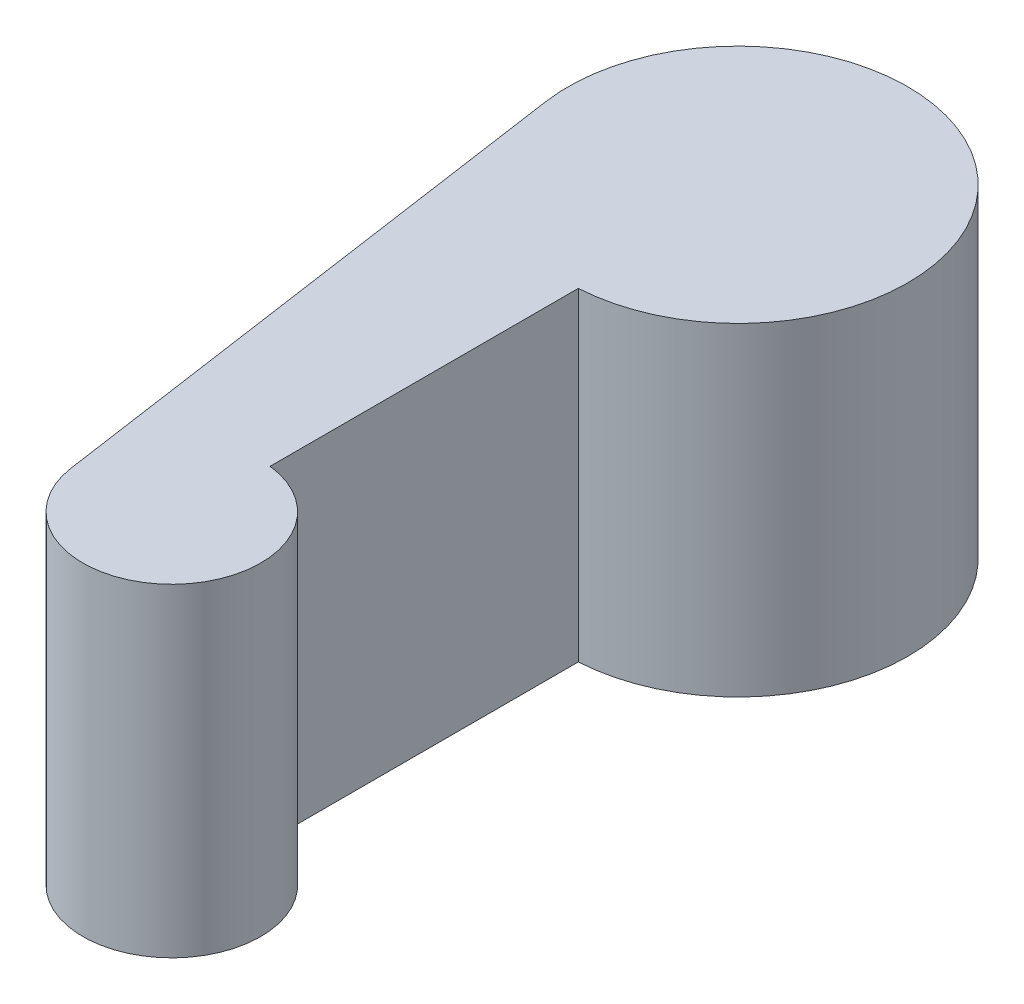
from build123d import *

# Parameters (mm, degrees)
BOSS_EXTRUDE1_DEPTH = 40


with BuildPart() as part:
    # Sketch1 → Boss-Extrude1 (new body)
    with BuildSketch(Plane(origin=(0, 0, 0), x_dir=(1, 0, 0), z_dir=(0, 1, 0))):
        with BuildLine():
            Line((-0.517406688, -35.397099854), (-0.517406688, 2.706237127))
            ThreePointArc((-0.517406688, 2.706237127), (11.543161609, 39.938087847), (-22.522046105, 20.67076735))
            Line((-22.522046105, 20.67076735), (-12.624612918, -47.900661221))
            ThreePointArc((-12.624612918, -47.900661221), (6.164980522, -53.981147872), (-0.517406688, -35.397099854))
        make_face()
    extrude(amount=BOSS_EXTRUDE1_DEPTH)


solid = part.part
